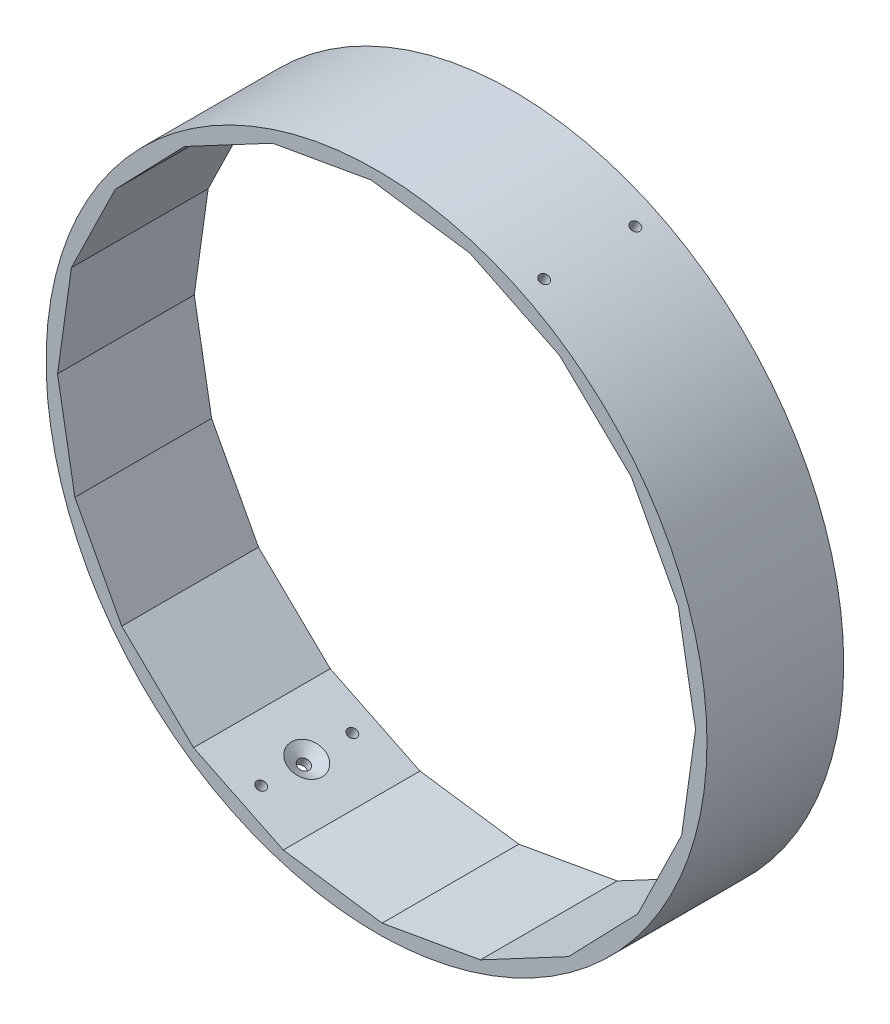
from build123d import *

# Parameters (mm, degrees)
IZIM1_R                     = 145
Y_KSEKLIK_EKSTR_ZYON1_DEPTH = 60
IZIM2_R                     = 2.5
KES_EKSTR_ZYON1_DEPTH       = 60
PAH2_SIZE                   = 5
PAH2_SIZE2                  = 2.886751346
IZIM3_R                     = 2.1
KES_EKSTR_ZYON3_DEPTH       = 326
KES_EKSTR_ZYON3_DEPTH_BACK  = 77


with BuildPart() as part:
    # Çizim1 → Yükseklik-Ekstrüzyon1 (new body)
    with BuildSketch(Plane.XY):
        Circle(IZIM1_R)
        Polygon((-114.6812862, 80.300701089), (-133.882665835, 40.932038661), (-139.978677322, -2.443336901), (-132.372600584, -45.579541624), (-111.808971407, -84.254103241), (-80.300701089, -114.6812862), (-40.932038661, -133.882665835), (2.443336901, -139.978677322), (45.579541624, -132.372600584), (84.254103241, -111.808971407), (114.6812862, -80.300701089), (133.882665835, -40.932038661), (139.978677322, 2.443336901), (132.372600584, 45.579541624), (111.808971407, 84.254103241), (80.300701089, 114.6812862), (40.932038661, 133.882665835), (-2.443336901, 139.978677322), (-45.579541624, 132.372600584), (-84.254103241, 111.808971407), align=None, mode=Mode.SUBTRACT)
    extrude(amount=Y_KSEKLIK_EKSTR_ZYON1_DEPTH)

    # Çizim2 → Kes-Ekstrüzyon1 (cut)
    with BuildSketch(Plane(origin=(-60.616369875, -124.281976018, 0), x_dir=(0.898794046, -0.438371147, 0), z_dir=(0.438371147, 0.898794046, 0))):
        with Locations((0, -30)):
            Circle(IZIM2_R)
    extrude(amount=-KES_EKSTR_ZYON1_DEPTH, mode=Mode.SUBTRACT)

    # Pah2
    pah2_edges = [part.edges().sort_by_distance(p)[0] for p in [
        (-62.863354991, -123.186048151, 30),
    ]]
    pah2_side = [part.faces().sort_by_distance(p)[0] for p in [
        (-79.633012371, -115.006939747, 30),
    ]]
    chamfer(pah2_edges, length=PAH2_SIZE, length2=PAH2_SIZE2, reference=pah2_side[0])

    # Çizim3 → Kes-Ekstrüzyon3 (cut, two sides)
    with BuildSketch(Plane(origin=(-60.616369875, -124.281976018, 0), x_dir=(0.898794046, -0.438371147, 0), z_dir=(0.438371147, 0.898794046, 0))) as kes_ekstr_zyon3_sk:
        with Locations((0, -10)):
            Circle(IZIM3_R)
        with Locations((0, -50)):
            Circle(IZIM3_R)
    extrude(amount=KES_EKSTR_ZYON3_DEPTH, mode=Mode.SUBTRACT)
    extrude(kes_ekstr_zyon3_sk.sketch, amount=-KES_EKSTR_ZYON3_DEPTH_BACK, mode=Mode.SUBTRACT)


solid = part.part
